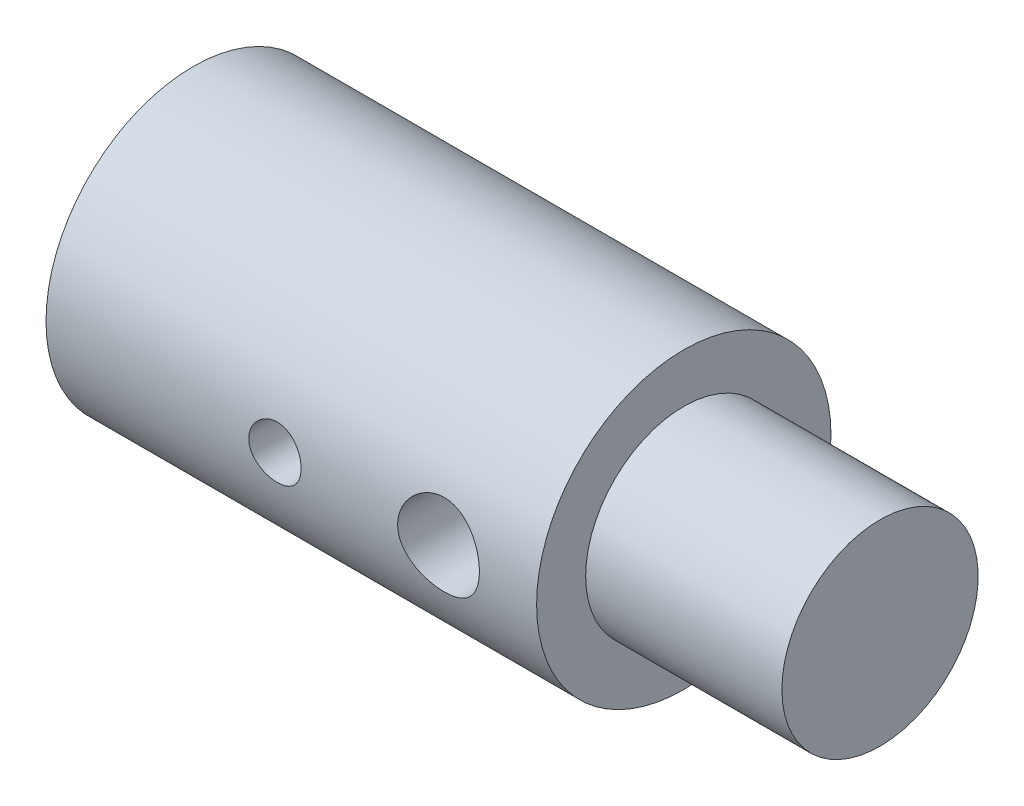
from build123d import *

# Parameters (mm, degrees)
SKIZZE5_W                            = 0.8
SKIZZE5_H                            = 4.5
SKIZZE7_R                            = 1.25
SCHNITT_LINEAR_AUSTRAGEN2_DEPTH      = 5.50000011
SCHNITT_LINEAR_AUSTRAGEN2_DEPTH_BACK = 5.5000001


with BuildPart() as part:
    # Skizze1 → Rotation1 (revolve)
    with BuildSketch(Plane.XY):
        Polygon((0, 4.5), (0, 2), (14, 2), (15.201721238, 0), (21, 0), (21, 3), (15, 3), (15, 4.5), align=None)
    revolve(axis=Axis((0, 0, 0), (1, 0, 0)))

    # Skizze5 → M2 Gewindebohrung1 (revolve, cut)
    with BuildSketch(Plane.YZ.offset(7)):
        with Locations((0.4, 2.25)):
            Rectangle(SKIZZE5_W, SKIZZE5_H)
    revolve(axis=Axis((7, 0, -6.35), (0, 0, 1)), mode=Mode.SUBTRACT)

    # Skizze7 → Schnitt-Linear austragen2 (cut, two sides)
    with BuildSketch(Plane.XY) as schnitt_linear_austragen2_sk:
        with Locations((12, 0)):
            Circle(SKIZZE7_R)
    extrude(amount=SCHNITT_LINEAR_AUSTRAGEN2_DEPTH, mode=Mode.SUBTRACT)
    extrude(schnitt_linear_austragen2_sk.sketch, amount=-SCHNITT_LINEAR_AUSTRAGEN2_DEPTH_BACK, mode=Mode.SUBTRACT)


solid = part.part
